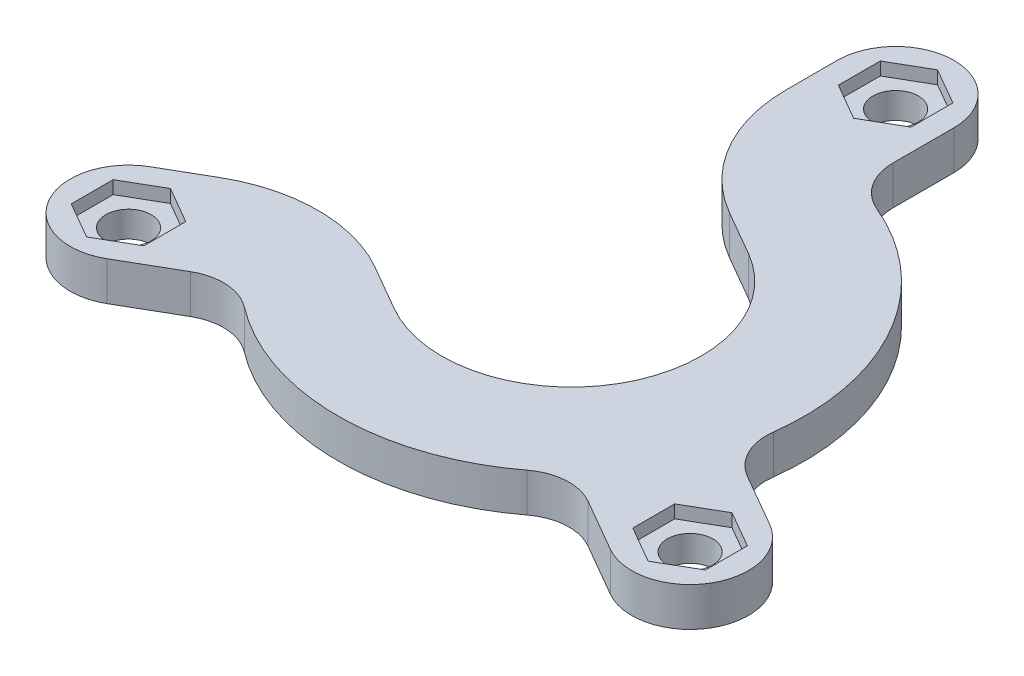
from build123d import *

# Parameters (mm, degrees)
SKETCH1_R           = 1.75
BOSS_EXTRUDE1_DEPTH = 3
CUT_EXTRUDE1_DEPTH  = 1


with BuildPart() as part:
    # Sketch1 → Boss-Extrude1 (new body)
    with BuildSketch(Plane(origin=(0, 0, 0), x_dir=(1, 0, 0), z_dir=(0, 1, 0))):
        with BuildLine():
            Line((23.900635095, -8.602885683), (19.823061771, -6.248697627))
            ThreePointArc((19.823061771, -6.248697627), (18.239104498, -4.560898425), (17.855232358, -2.278305828))
            ThreePointArc((17.855232358, -2.278305828), (15.588457268, 9), (6.954545455, 16.602237726))
            ThreePointArc((6.954545455, 16.602237726), (5.169698348, 18.07597705), (4.5, 20.291623888))
            Line((4.5, 20.291623888), (4.5, 25))
            ThreePointArc((4.5, 25), (0, 29.5), (-4.5, 25))
            Line((-4.5, 25), (-4.5, 21.073284825))
            ThreePointArc((-4.5, 21.073284825), (-2.892304845, 15.073284825), (1.5, 10.68097998))
            Line((1.5, 10.68097998), (5, 8.660254038))
            ThreePointArc((5, 8.660254038), (8.660254038, -5), (-5, -8.660254038))
            Line((-5, -8.660254038), (-8.5, -6.639528096))
            ThreePointArc((-8.5, -6.639528096), (-14.5, -5.031832941), (-20.5, -6.639528096))
            Line((-20.5, -6.639528096), (-23.900635095, -8.602885683))
            ThreePointArc((-23.900635095, -8.602885683), (-25.547749412, -14.75), (-19.400635095, -16.397114317))
            Line((-19.400635095, -16.397114317), (-15.323061771, -14.042926261))
            ThreePointArc((-15.323061771, -14.042926261), (-13.069406149, -13.515078625), (-10.900686903, -14.323931899))
            ThreePointArc((-10.900686903, -14.323931899), (0, -18), (10.900686903, -14.323931899))
            ThreePointArc((10.900686903, -14.323931899), (13.069406149, -13.515078625), (15.323061771, -14.042926261))
            Line((15.323061771, -14.042926261), (19.400635095, -16.397114317))
            ThreePointArc((19.400635095, -16.397114317), (25.547749412, -14.75), (23.900635095, -8.602885683))
        make_face()
        with Locations((0, 25)):
            Circle(SKETCH1_R, mode=Mode.SUBTRACT)
        with Locations((21.650635095, -12.5)):
            Circle(SKETCH1_R, mode=Mode.SUBTRACT)
        with Locations((-21.650635095, -12.5)):
            Circle(SKETCH1_R, mode=Mode.SUBTRACT)
    extrude(amount=BOSS_EXTRUDE1_DEPTH)

    # Sketch2 → Cut-Extrude1 (cut)
    with BuildSketch(Plane(origin=(0, 3, 0), x_dir=(1, 0, 0), z_dir=(0, 1, 0))):
        Polygon((2.8, 23.383419246), (2.8, 26.616580754), (0, 28.233161507), (-2.8, 26.616580754), (-2.8, 23.383419246), (0, 21.766838493), align=None)
        Polygon((24.450635095, -14.116580754), (24.450635095, -10.883419246), (21.650635095, -9.266838493), (18.850635095, -10.883419246), (18.850635095, -14.116580754), (21.650635095, -15.733161507), align=None)
        Polygon((-24.450635095, -14.116580754), (-21.650635095, -15.733161507), (-18.850635095, -14.116580754), (-18.850635095, -10.883419246), (-21.650635095, -9.266838493), (-24.450635095, -10.883419246), align=None)
    extrude(amount=-CUT_EXTRUDE1_DEPTH, mode=Mode.SUBTRACT)


solid = part.part
